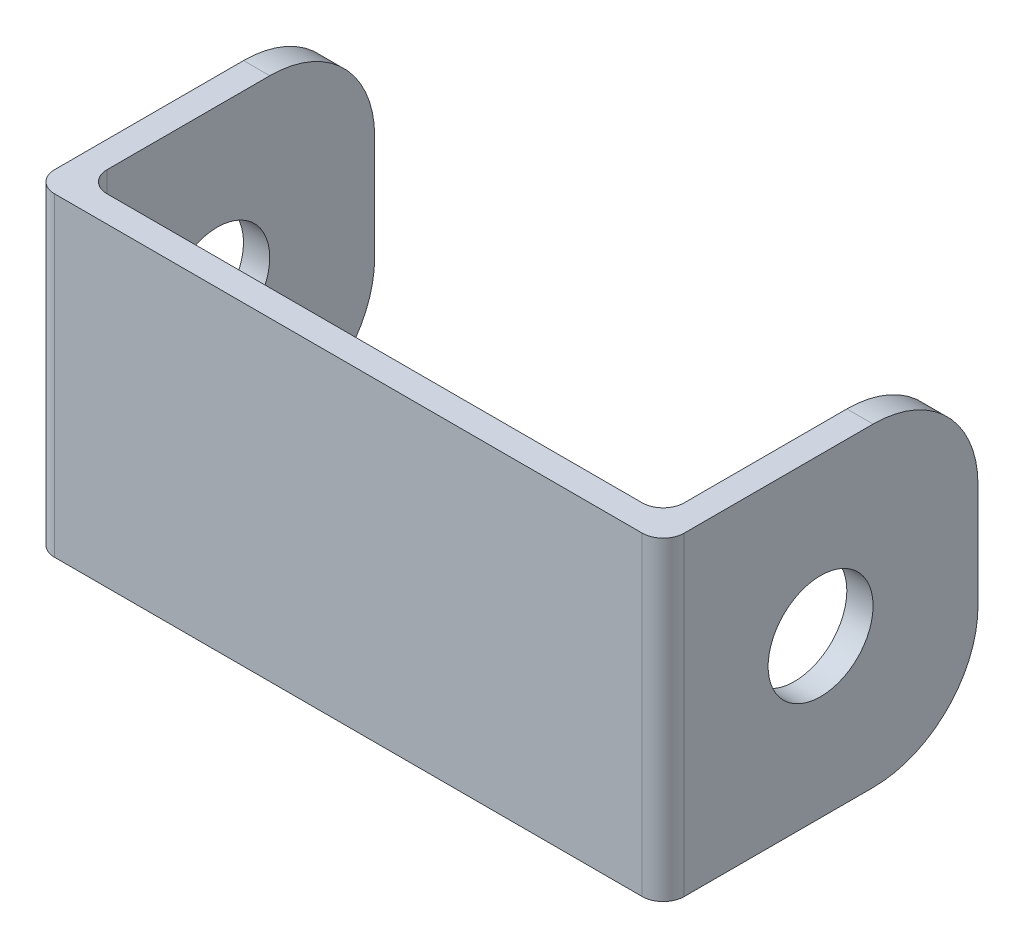
from build123d import *

# Parameters (mm, degrees)
BOSS_EXTRUDE1_DEPTH = 38.1
SKETCH4_R           = 6.35
CUT_EXTRUDE1_DEPTH  = 77.2
FILLET1_R           = 12.7
FILLET2_R           = 2.54


with BuildPart() as part:
    # Sketch1 → Boss-Extrude1 (new body)
    with BuildSketch(Plane(origin=(0, 0, 0), x_dir=(1, 0, 0), z_dir=(0, 1, 0))):
        Polygon((-5.55625, 27.9796875), (-5.55625, -10.1203125), (70.64375, -10.1203125), (70.64375, 27.9796875), (67.46875, 27.9796875), (67.46875, -6.9453125), (-2.38125, -6.9453125), (-2.38125, 27.9796875), align=None)
    extrude(amount=BOSS_EXTRUDE1_DEPTH)

    # Sketch4 → Cut-Extrude1 (cut, through all)
    with BuildSketch(Plane(origin=(70.64375, 0, 0), x_dir=(0, 0, -1), z_dir=(1, 0, 0))):
        with Locations((8.9296875, 19.05)):
            Circle(SKETCH4_R)
    extrude(amount=-CUT_EXTRUDE1_DEPTH, mode=Mode.SUBTRACT)

    # Fillet1
    fillet1_edges = [part.edges().sort_by_distance(p)[0] for p in [
        (-3.96875, 0, -27.9796875),
        (69.05625, 38.1, -27.9796875),
        (-3.96875, 38.1, -27.9796875),
        (69.05625, 0, -27.9796875),
    ]]
    fillet(fillet1_edges, radius=FILLET1_R)

    # Fillet2
    fillet2_edges = [part.edges().sort_by_distance(p)[0] for p in [
        (-2.38125, 19.05, 6.9453125),
        (67.46875, 19.05, 6.9453125),
        (70.64375, 19.05, 10.1203125),
        (-5.55625, 19.05, 10.1203125),
    ]]
    fillet(fillet2_edges, radius=FILLET2_R)


solid = part.part
